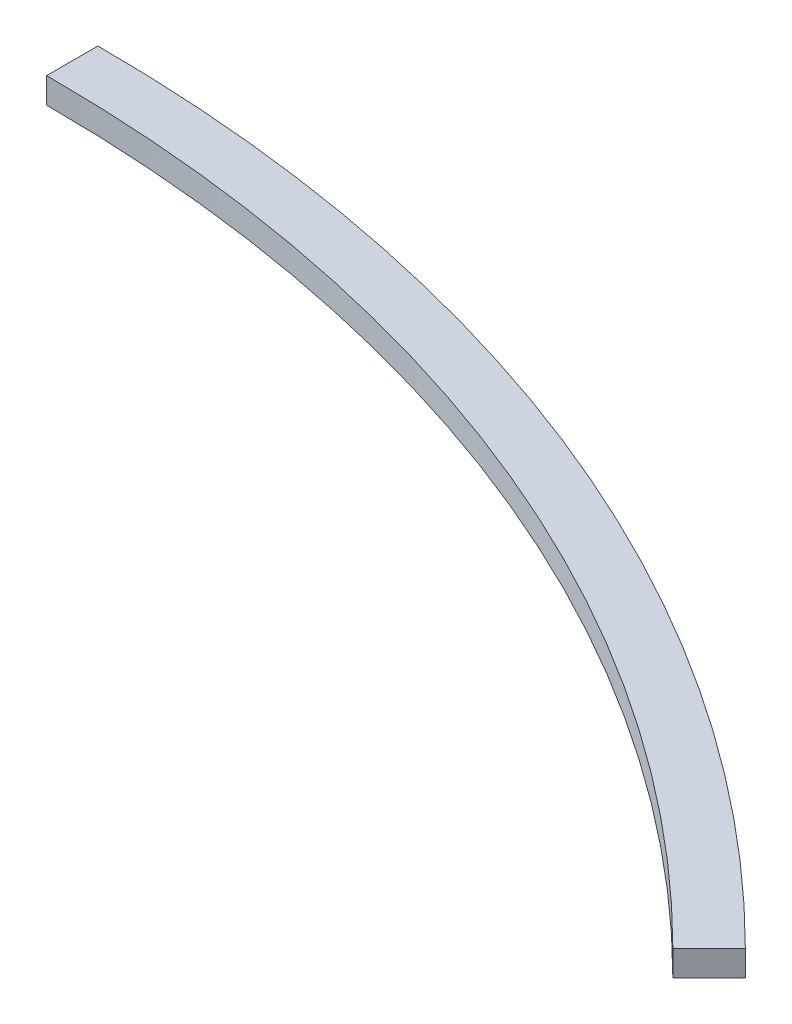
from build123d import *

# Parameters (mm, degrees)
BOSS_EXTRUDE1_DEPTH = 10


with BuildPart() as part:
    # Sketch1 → Boss-Extrude1 (new body)
    with BuildSketch(Plane(origin=(0, 0, 0), x_dir=(1, 0, 0), z_dir=(0, 1, 0))):
        with BuildLine():
            ThreePointArc((0, 610), (233.436893743, 563.566514832), (431.335136524, 431.335136524))
            Line((431.335136524, 431.335136524), (417.1930009, 417.1930009))
            ThreePointArc((417.1930009, 417.1930009), (225.783225095, 545.088924182), (0, 590))
            Line((0, 590), (0, 610))
        make_face()
    extrude(amount=BOSS_EXTRUDE1_DEPTH)


solid = part.part
